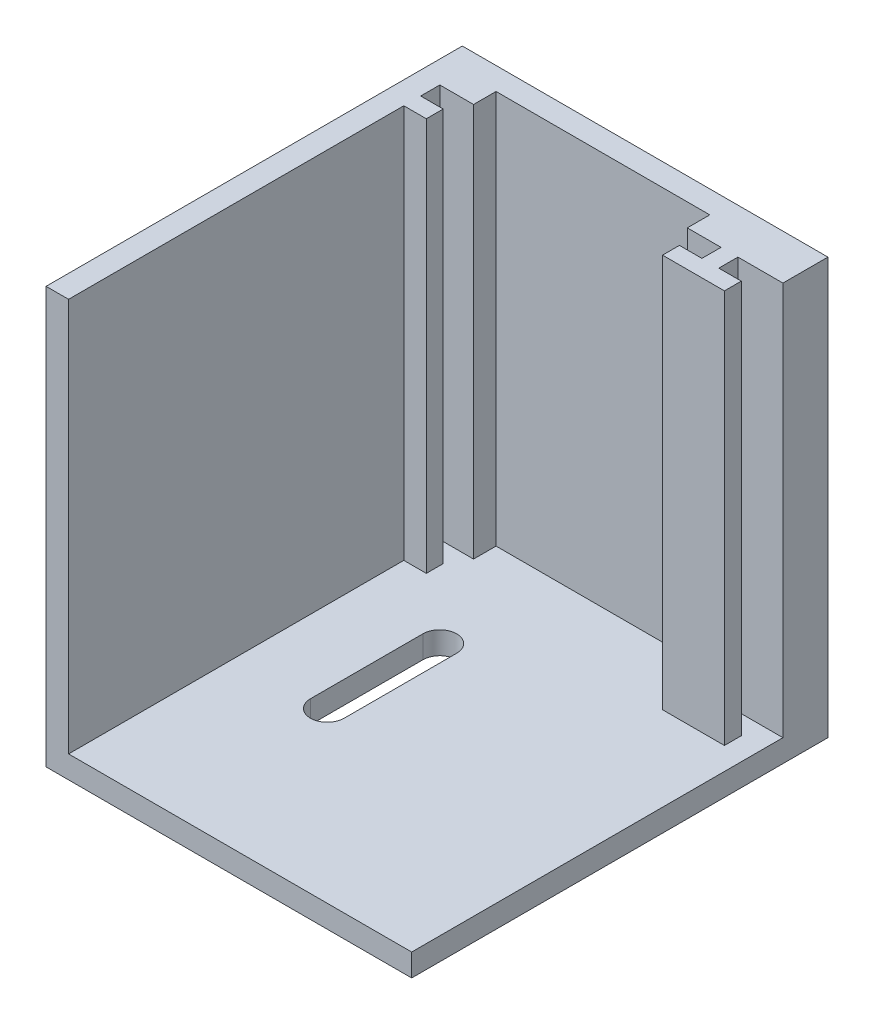
from build123d import *

# Parameters (mm, degrees)
SKETCH1_W           = 29
SKETCH1_H           = 35
BOSS_EXTRUDE1_DEPTH = 2
SKETCH4_W           = 3
SKETCH4_H           = 35
BOSS_EXTRUDE3_DEPTH = 2
SKETCH5_W           = 3.5
SKETCH5_H           = 1.5
SKETCH5_W_2         = 1.5
SKETCH5_H_2         = 3.7
BOSS_EXTRUDE4_DEPTH = 35
SKETCH6_W           = 2
SKETCH6_H           = 35
BOSS_EXTRUDE5_DEPTH = 35
SKETCH7_W           = 32.5
SKETCH7_H           = 2
BOSS_EXTRUDE6_DEPTH = 37
CUT_EXTRUDE1_DEPTH  = 38
SKETCH11_W          = 2
SKETCH11_H          = 1.5
SKETCH11_W_2        = 3
SKETCH11_H_2        = 2
BOSS_EXTRUDE7_DEPTH = 35
SKETCH12_W          = 3.5
SKETCH12_H          = 2
SKETCH12_W_2        = 1
BOSS_EXTRUDE8_DEPTH = 35


with BuildPart() as part:
    # Sketch1 → Boss-Extrude1 (new body)
    with BuildSketch(Plane.XY):
        with Locations((0, 1.5)):
            Rectangle(SKETCH1_W, SKETCH1_H)
    extrude(amount=BOSS_EXTRUDE1_DEPTH)

    # Sketch4 → Boss-Extrude3 (add)
    with BuildSketch(Plane.XY.offset(2)):
        with Locations((-11, 1.5)):
            Rectangle(SKETCH4_W, SKETCH4_H)
        with Locations((11, 1.5)):
            Rectangle(SKETCH4_W, SKETCH4_H)
    extrude(amount=BOSS_EXTRUDE3_DEPTH)

    # Sketch5 → Boss-Extrude4 (add, through all)
    with BuildSketch(Plane(origin=(0, 19, 0), x_dir=(1, 0, 0), z_dir=(0, 1, 0))):
        Polygon((-12.5, -5.7), (-14, -5.7), (-14, -7.2), (-10.5, -7.2), (-10.5, -5.7), align=None)
        Polygon((-12.5, -4), (-12.5, -2), (-14, -2), (-14, -5.7), (-12.5, -5.7), align=None)
        with Locations((12.25, -6.45)):
            Rectangle(SKETCH5_W, SKETCH5_H)
        with Locations((13.25, -3.85)):
            Rectangle(SKETCH5_W_2, SKETCH5_H_2)
    extrude(amount=-BOSS_EXTRUDE4_DEPTH)

    # Sketch6 → Boss-Extrude5 (add)
    with BuildSketch(Plane.XY.offset(2)):
        with Locations((-13.5, 1.5)):
            Rectangle(SKETCH6_W, SKETCH6_H)
    extrude(amount=BOSS_EXTRUDE5_DEPTH)

    # Sketch7 → Boss-Extrude6 (add)
    with BuildSketch(Plane.XY):
        with Locations((1.75, -17)):
            Rectangle(SKETCH7_W, SKETCH7_H)
    extrude(amount=BOSS_EXTRUDE6_DEPTH)

    # Sketch8 → Cut-Extrude1 (cut, through all)
    with BuildSketch(Plane(origin=(0, -18, 0), x_dir=(-1, 0, 0), z_dir=(0, -1, 0))):
        with BuildLine():
            Line((6, -12), (6, -22))
            ThreePointArc((6, -22), (4.5, -23.5), (3, -22))
            Line((3, -22), (3, -12))
            ThreePointArc((3, -12), (4.5, -10.5), (6, -12))
        make_face()
    extrude(amount=-CUT_EXTRUDE1_DEPTH, mode=Mode.SUBTRACT)

    # Sketch11 → Boss-Extrude7 (add)
    with BuildSketch(Plane(origin=(0, 19, 0), x_dir=(-1, 0, 0), z_dir=(0, -1, 0))):
        with Locations((-15, -6.45)):
            Rectangle(SKETCH11_W, SKETCH11_H)
        with Locations((-15.5, -3)):
            Rectangle(SKETCH11_W_2, SKETCH11_H_2)
    extrude(amount=BOSS_EXTRUDE7_DEPTH)

    # Sketch12 → Boss-Extrude8 (add)
    with BuildSketch(Plane(origin=(0, 19, 0), x_dir=(-1, 0, 0), z_dir=(0, -1, 0))):
        with Locations((-16.25, -1)):
            Rectangle(SKETCH12_W, SKETCH12_H)
        with Locations((-17.5, -3)):
            Rectangle(SKETCH12_W_2, SKETCH12_H)
    extrude(amount=BOSS_EXTRUDE8_DEPTH)


solid = part.part
